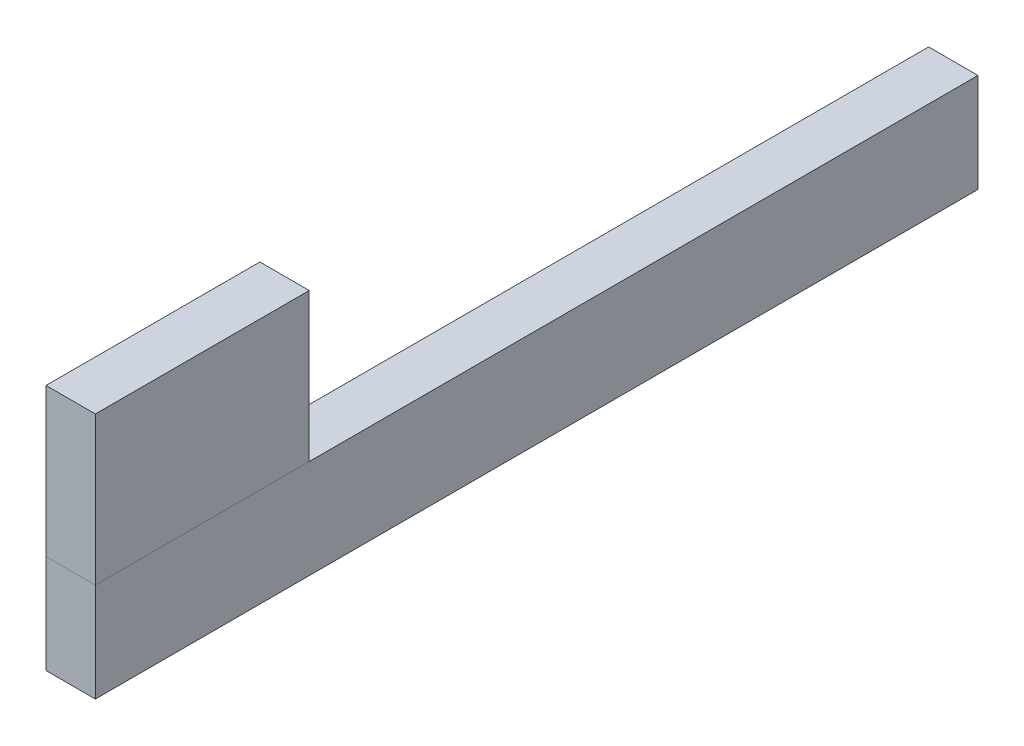
from build123d import *

# Parameters (mm, degrees)
SKETCH1_W           = 25.4
SKETCH1_H           = 50.8
BOSS_EXTRUDE1_DEPTH = 454
SKETCH2_W           = 25.4
SKETCH2_H           = 110
BOSS_EXTRUDE2_DEPTH = 76.2


with BuildPart() as part:
    # Sketch1 → Boss-Extrude1 (new body)
    with BuildSketch(Plane.XY):
        Rectangle(SKETCH1_W, SKETCH1_H)
    extrude(amount=BOSS_EXTRUDE1_DEPTH)


with BuildPart() as body_2:
    # Sketch2 → Boss-Extrude2 (new body)
    with BuildSketch(Plane(origin=(0, 25.4, 0), x_dir=(1, 0, 0), z_dir=(0, 1, 0))):
        with Locations((0, -399)):
            Rectangle(SKETCH2_W, SKETCH2_H)
    extrude(amount=BOSS_EXTRUDE2_DEPTH)


solid = Compound([part.part, body_2.part])
